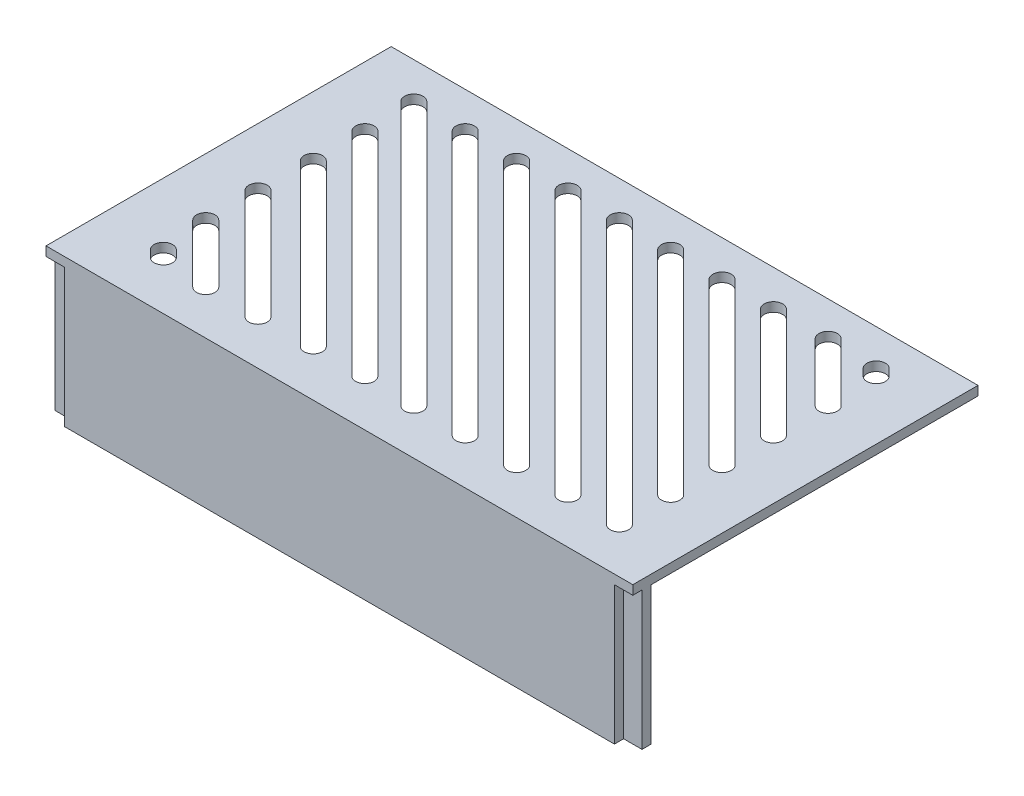
from build123d import *

# Parameters (mm, degrees)
SKETCH1_W           = 63.75
SKETCH1_H           = 36.5
BOSS_EXTRUDE1_DEPTH = 1
SKETCH2_W           = 63.75
SKETCH2_H           = 1
BOSS_EXTRUDE2_DEPTH = 15
BOSS_EXTRUDE3_DEPTH = 1
CUT_EXTRUDE1_REACH  = 18


with BuildPart() as part:
    # Sketch1 → Boss-Extrude1 (new body)
    with BuildSketch(Plane(origin=(0, 0, 0), x_dir=(1, 0, 0), z_dir=(0, 1, 0))):
        Rectangle(SKETCH1_W, SKETCH1_H)
    extrude(amount=-BOSS_EXTRUDE1_DEPTH)

    # Sketch2 → Boss-Extrude2 (add)
    with BuildSketch(Plane(origin=(0, -1, 0), x_dir=(-1, 0, 0), z_dir=(0, -1, 0))):
        with Locations((0, -17.75)):
            Rectangle(SKETCH2_W, SKETCH2_H)
    extrude(amount=BOSS_EXTRUDE2_DEPTH)

    # Sketch3 → Boss-Extrude3 (add)
    with BuildSketch(Plane.XY.offset(18.25)):
        Polygon((-31.875, 0), (31.875, 0), (31.875, -1), (29.875, -1), (29.875, -16), (-29.875, -16), (-29.875, -1), (-31.875, -1), align=None)
    extrude(amount=BOSS_EXTRUDE3_DEPTH)

    # Sketch4 → Cut-Extrude1 (cut, up to next)
    with BuildSketch(Plane(origin=(0, 0, 0), x_dir=(1, 0, 0), z_dir=(0, 1, 0)), mode=Mode.PRIVATE) as cut_extrude1_sk1:
        with BuildLine():
            Line((-23.706953695, -13.257748955), (-24.425558305, -12.539144346))
            ThreePointArc((-24.425558305, -12.539144346), (-25.839771867, -12.539144346), (-25.839771867, -13.953357908))
            Line((-25.839771867, -13.953357908), (-25.121167258, -14.671962518))
            ThreePointArc((-25.121167258, -14.671962518), (-23.706953695, -14.671962518), (-23.706953695, -13.257748955))
        make_face()
    cut_extrude1_tool1 = extrude(cut_extrude1_sk1.sketch, amount=-CUT_EXTRUDE1_REACH, mode=Mode.PRIVATE) & part.part
    add(cut_extrude1_tool1.solids().sort_by_distance((-24.773363, 0, 13.605553))[0], mode=Mode.SUBTRACT)
    # Sketch4 → Cut-Extrude1 (cut, up to next)
    with BuildSketch(Plane(origin=(0, 0, 0), x_dir=(1, 0, 0), z_dir=(0, 1, 0)), mode=Mode.PRIVATE) as cut_extrude1_sk2:
        with BuildLine():
            Line((-18.612300872, -13.743096131), (-24.910905481, -7.444491522))
            ThreePointArc((-24.910905481, -7.444491522), (-26.325119043, -7.444491522), (-26.325119043, -8.858705084))
            Line((-26.325119043, -8.858705084), (-20.026514434, -15.157309694))
            ThreePointArc((-20.026514434, -15.157309694), (-18.612300872, -15.157309694), (-18.612300872, -13.743096131))
        make_face()
    cut_extrude1_tool2 = extrude(cut_extrude1_sk2.sketch, amount=-CUT_EXTRUDE1_REACH, mode=Mode.PRIVATE) & part.part
    add(cut_extrude1_tool2.solids().sort_by_distance((-22.46871, 0, 11.300901))[0], mode=Mode.SUBTRACT)
    # Sketch4 → Cut-Extrude1 (cut, up to next)
    with BuildSketch(Plane(origin=(0, 0, 0), x_dir=(1, 0, 0), z_dir=(0, 1, 0)), mode=Mode.PRIVATE) as cut_extrude1_sk3:
        with BuildLine():
            Line((-12.983889235, -13.694684495), (-24.862493845, -1.816079885))
            ThreePointArc((-24.862493845, -1.816079885), (-26.276707407, -1.816079885), (-26.276707407, -3.230293448))
            Line((-26.276707407, -3.230293448), (-14.398102798, -15.108898057))
            ThreePointArc((-14.398102798, -15.108898057), (-12.983889235, -15.108898057), (-12.983889235, -13.694684495))
        make_face()
    cut_extrude1_tool3 = extrude(cut_extrude1_sk3.sketch, amount=-CUT_EXTRUDE1_REACH, mode=Mode.PRIVATE) & part.part
    add(cut_extrude1_tool3.solids().sort_by_distance((-19.630298, 0, 8.462489))[0], mode=Mode.SUBTRACT)
    # Sketch4 → Cut-Extrude1 (cut, up to next)
    with BuildSketch(Plane(origin=(0, 0, 0), x_dir=(1, 0, 0), z_dir=(0, 1, 0)), mode=Mode.PRIVATE) as cut_extrude1_sk4:
        with BuildLine():
            Line((-7.19192546, -13.482720719), (-24.650530069, 3.97588389))
            ThreePointArc((-24.650530069, 3.97588389), (-26.064743631, 3.97588389), (-26.064743631, 2.561670328))
            Line((-26.064743631, 2.561670328), (-8.606139022, -14.896934282))
            ThreePointArc((-8.606139022, -14.896934282), (-7.19192546, -14.896934282), (-7.19192546, -13.482720719))
        make_face()
    cut_extrude1_tool4 = extrude(cut_extrude1_sk4.sketch, amount=-CUT_EXTRUDE1_REACH, mode=Mode.PRIVATE) & part.part
    add(cut_extrude1_tool4.solids().sort_by_distance((-16.628335, 0, 5.460525))[0], mode=Mode.SUBTRACT)
    # Sketch4 → Cut-Extrude1 (cut, up to next)
    with BuildSketch(Plane(origin=(0, 0, 0), x_dir=(1, 0, 0), z_dir=(0, 1, 0)), mode=Mode.PRIVATE) as cut_extrude1_sk5:
        with BuildLine():
            Line((-1.598647721, -13.469442981), (-24.63725233, 9.569161629))
            ThreePointArc((-24.63725233, 9.569161629), (-26.051465893, 9.569161629), (-26.051465893, 8.154948066))
            Line((-26.051465893, 8.154948066), (-3.012861283, -14.883656543))
            ThreePointArc((-3.012861283, -14.883656543), (-1.598647721, -14.883656543), (-1.598647721, -13.469442981))
        make_face()
    cut_extrude1_tool5 = extrude(cut_extrude1_sk5.sketch, amount=-CUT_EXTRUDE1_REACH, mode=Mode.PRIVATE) & part.part
    add(cut_extrude1_tool5.solids().sort_by_distance((-13.825057, 0, 2.657247))[0], mode=Mode.SUBTRACT)
    # Sketch4 → Cut-Extrude1 (cut, up to next)
    with BuildSketch(Plane(origin=(0, 0, 0), x_dir=(1, 0, 0), z_dir=(0, 1, 0)), mode=Mode.PRIVATE) as cut_extrude1_sk6:
        with BuildLine():
            Line((3.848599736, -13.602195524), (-24.770004873, 15.016409086))
            ThreePointArc((-24.770004873, 15.016409086), (-26.184218436, 15.016409086), (-26.184218436, 13.602195524))
            Line((-26.184218436, 13.602195524), (2.434386174, -15.016409086))
            ThreePointArc((2.434386174, -15.016409086), (3.848599736, -15.016409086), (3.848599736, -13.602195524))
        make_face()
    cut_extrude1_tool6 = extrude(cut_extrude1_sk6.sketch, amount=-CUT_EXTRUDE1_REACH, mode=Mode.PRIVATE) & part.part
    add(cut_extrude1_tool6.solids().sort_by_distance((-11.167809, 0, 0))[0], mode=Mode.SUBTRACT)
    # Sketch4 → Cut-Extrude1 (cut, up to next)
    with BuildSketch(Plane(origin=(0, 0, 0), x_dir=(1, 0, 0), z_dir=(0, 1, 0)), mode=Mode.PRIVATE) as cut_extrude1_sk7:
        with BuildLine():
            Line((9.432504411, -13.602195524), (-19.186100198, 15.016409086))
            ThreePointArc((-19.186100198, 15.016409086), (-20.600313761, 15.016409086), (-20.600313761, 13.602195524))
            Line((-20.600313761, 13.602195524), (8.018290849, -15.016409086))
            ThreePointArc((8.018290849, -15.016409086), (9.432504411, -15.016409086), (9.432504411, -13.602195524))
        make_face()
    cut_extrude1_tool7 = extrude(cut_extrude1_sk7.sketch, amount=-CUT_EXTRUDE1_REACH, mode=Mode.PRIVATE) & part.part
    add(cut_extrude1_tool7.solids().sort_by_distance((-5.583905, 0, 0))[0], mode=Mode.SUBTRACT)
    # Sketch4 → Cut-Extrude1 (cut, up to next)
    with BuildSketch(Plane(origin=(0, 0, 0), x_dir=(1, 0, 0), z_dir=(0, 1, 0)), mode=Mode.PRIVATE) as cut_extrude1_sk8:
        with BuildLine():
            Line((15.016409086, -13.602195524), (-13.602195524, 15.016409086))
            ThreePointArc((-13.602195524, 15.016409086), (-15.016409086, 15.016409086), (-15.016409086, 13.602195524))
            Line((-15.016409086, 13.602195524), (13.602195524, -15.016409086))
            ThreePointArc((13.602195524, -15.016409086), (15.016409086, -15.016409086), (15.016409086, -13.602195524))
        make_face()
    cut_extrude1_tool8 = extrude(cut_extrude1_sk8.sketch, amount=-CUT_EXTRUDE1_REACH, mode=Mode.PRIVATE) & part.part
    add(cut_extrude1_tool8.solids().sort_by_distance((0, 0, 0))[0], mode=Mode.SUBTRACT)
    # Sketch4 → Cut-Extrude1 (cut, up to next)
    with BuildSketch(Plane(origin=(0, 0, 0), x_dir=(1, 0, 0), z_dir=(0, 1, 0)), mode=Mode.PRIVATE) as cut_extrude1_sk9:
        with BuildLine():
            Line((20.596409086, -13.602195524), (-8.022195524, 15.016409086))
            ThreePointArc((-8.022195524, 15.016409086), (-9.436409086, 15.016409086), (-9.436409086, 13.602195524))
            Line((-9.436409086, 13.602195524), (19.182195524, -15.016409086))
            ThreePointArc((19.182195524, -15.016409086), (20.596409086, -15.016409086), (20.596409086, -13.602195524))
        make_face()
    cut_extrude1_tool9 = extrude(cut_extrude1_sk9.sketch, amount=-CUT_EXTRUDE1_REACH, mode=Mode.PRIVATE) & part.part
    add(cut_extrude1_tool9.solids().sort_by_distance((5.58, 0, 0))[0], mode=Mode.SUBTRACT)
    # Sketch4 → Cut-Extrude1 (cut, up to next)
    with BuildSketch(Plane(origin=(0, 0, 0), x_dir=(1, 0, 0), z_dir=(0, 1, 0)), mode=Mode.PRIVATE) as cut_extrude1_sk10:
        with BuildLine():
            Line((26.184121966, -13.602099067), (-2.442291993, 15.016505543))
            ThreePointArc((-2.442291993, 15.016505543), (-3.856505543, 15.016312616), (-3.856312616, 13.602099067))
            Line((-3.856312616, 13.602099067), (24.770101343, -15.016505543))
            ThreePointArc((24.770101343, -15.016505543), (26.184314892, -15.016312616), (26.184121966, -13.602099067))
        make_face()
    cut_extrude1_tool10 = extrude(cut_extrude1_sk10.sketch, amount=-CUT_EXTRUDE1_REACH, mode=Mode.PRIVATE) & part.part
    add(cut_extrude1_tool10.solids().sort_by_distance((11.163905, 0, 0))[0], mode=Mode.SUBTRACT)
    # Sketch4 → Cut-Extrude1 (cut, up to next)
    with BuildSketch(Plane(origin=(0, 0, 0), x_dir=(1, 0, 0), z_dir=(0, 1, 0)), mode=Mode.PRIVATE) as cut_extrude1_sk11:
        with BuildLine():
            Line((26.184218436, -8.030004873), (3.137804476, 15.016409086))
            ThreePointArc((3.137804476, 15.016409086), (1.723590914, 15.016409086), (1.723590914, 13.602195524))
            Line((1.723590914, 13.602195524), (24.770004873, -9.444218436))
            ThreePointArc((24.770004873, -9.444218436), (26.184218436, -9.444218436), (26.184218436, -8.030004873))
        make_face()
    cut_extrude1_tool11 = extrude(cut_extrude1_sk11.sketch, amount=-CUT_EXTRUDE1_REACH, mode=Mode.PRIVATE) & part.part
    add(cut_extrude1_tool11.solids().sort_by_distance((13.953905, 0, -2.786095))[0], mode=Mode.SUBTRACT)
    # Sketch4 → Cut-Extrude1 (cut, up to next)
    with BuildSketch(Plane(origin=(0, 0, 0), x_dir=(1, 0, 0), z_dir=(0, 1, 0)), mode=Mode.PRIVATE) as cut_extrude1_sk12:
        with BuildLine():
            Line((26.184218436, -2.450004873), (8.717804476, 15.016409086))
            ThreePointArc((8.717804476, 15.016409086), (7.303590914, 15.016409086), (7.303590914, 13.602195524))
            Line((7.303590914, 13.602195524), (24.770004873, -3.864218436))
            ThreePointArc((24.770004873, -3.864218436), (26.184218436, -3.864218436), (26.184218436, -2.450004873))
        make_face()
    cut_extrude1_tool12 = extrude(cut_extrude1_sk12.sketch, amount=-CUT_EXTRUDE1_REACH, mode=Mode.PRIVATE) & part.part
    add(cut_extrude1_tool12.solids().sort_by_distance((16.743905, 0, -5.576095))[0], mode=Mode.SUBTRACT)
    # Sketch4 → Cut-Extrude1 (cut, up to next)
    with BuildSketch(Plane(origin=(0, 0, 0), x_dir=(1, 0, 0), z_dir=(0, 1, 0)), mode=Mode.PRIVATE) as cut_extrude1_sk13:
        with BuildLine():
            Line((26.184218436, 3.129995127), (14.297804476, 15.016409086))
            ThreePointArc((14.297804476, 15.016409086), (12.883590914, 15.016409086), (12.883590914, 13.602195524))
            Line((12.883590914, 13.602195524), (24.770004873, 1.715781564))
            ThreePointArc((24.770004873, 1.715781564), (26.184218436, 1.715781564), (26.184218436, 3.129995127))
        make_face()
    cut_extrude1_tool13 = extrude(cut_extrude1_sk13.sketch, amount=-CUT_EXTRUDE1_REACH, mode=Mode.PRIVATE) & part.part
    add(cut_extrude1_tool13.solids().sort_by_distance((19.533905, 0, -8.366095))[0], mode=Mode.SUBTRACT)
    # Sketch4 → Cut-Extrude1 (cut, up to next)
    with BuildSketch(Plane(origin=(0, 0, 0), x_dir=(1, 0, 0), z_dir=(0, 1, 0)), mode=Mode.PRIVATE) as cut_extrude1_sk14:
        with BuildLine():
            Line((26.369863641, 8.895640332), (20.063449682, 15.202054291))
            ThreePointArc((20.063449682, 15.202054291), (18.64923612, 15.202054291), (18.64923612, 13.787840729))
            Line((18.64923612, 13.787840729), (24.955650079, 7.48142677))
            ThreePointArc((24.955650079, 7.48142677), (26.369863641, 7.48142677), (26.369863641, 8.895640332))
        make_face()
    cut_extrude1_tool14 = extrude(cut_extrude1_sk14.sketch, amount=-CUT_EXTRUDE1_REACH, mode=Mode.PRIVATE) & part.part
    add(cut_extrude1_tool14.solids().sort_by_distance((22.50955, 0, -11.341741))[0], mode=Mode.SUBTRACT)
    # Sketch4 → Cut-Extrude1 (cut, up to next)
    with BuildSketch(Plane(origin=(0, 0, 0), x_dir=(1, 0, 0), z_dir=(0, 1, 0)), mode=Mode.PRIVATE) as cut_extrude1_sk15:
        with BuildLine():
            Line((26.184218436, 14.289995127), (25.457804476, 15.016409086))
            ThreePointArc((25.457804476, 15.016409086), (24.043590914, 15.016409086), (24.043590914, 13.602195524))
            Line((24.043590914, 13.602195524), (24.770004873, 12.875781564))
            ThreePointArc((24.770004873, 12.875781564), (26.184218436, 12.875781564), (26.184218436, 14.289995127))
        make_face()
    cut_extrude1_tool15 = extrude(cut_extrude1_sk15.sketch, amount=-CUT_EXTRUDE1_REACH, mode=Mode.PRIVATE) & part.part
    add(cut_extrude1_tool15.solids().sort_by_distance((25.113905, 0, -13.946095))[0], mode=Mode.SUBTRACT)


solid = part.part
